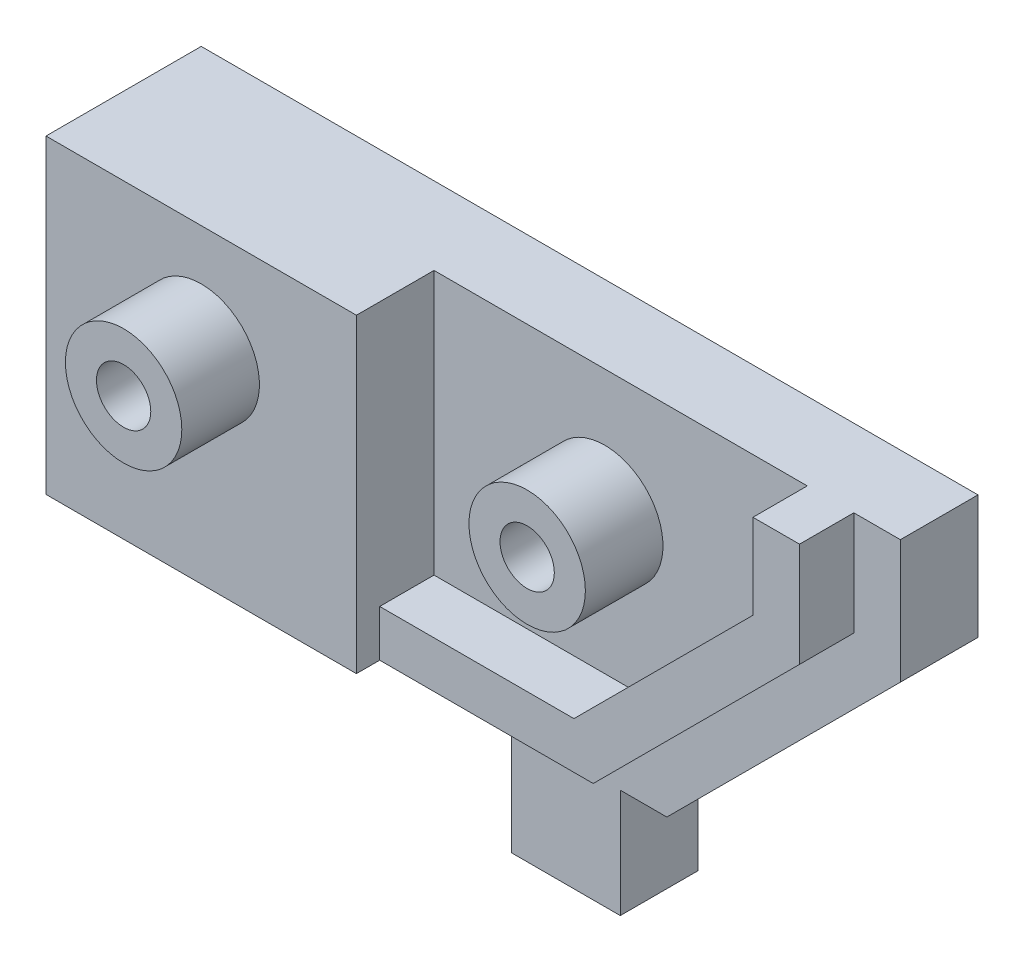
from build123d import *

# Parameters (mm, degrees)
BOSS_EXTRUDE1_DEPTH = 23
SKETCH2_R           = 1.75
CUT_EXTRUDE1_DEPTH  = 11
SKETCH3_R           = 1.5
CUT_EXTRUDE2_DEPTH  = 10
SKETCH4_W           = 7
SKETCH4_H           = 5
BOSS_EXTRUDE2_DEPTH = 7
SKETCH5_R           = 3.75
SKETCH5_R_2         = 1.75
BOSS_EXTRUDE3_DEPTH = 5
SKETCH6_R           = 3.75
SKETCH6_R_2         = 1.75
BOSS_EXTRUDE4_DEPTH = 5
BOSS_EXTRUDE5_DEPTH = 5
BOSS_EXTRUDE6_DEPTH = 3.5
SKETCH9_W           = 5
SKETCH9_H           = 3
CUT_EXTRUDE3_DEPTH  = 20


with BuildPart() as part:
    # Sketch1 → Boss-Extrude1 (new body)
    with BuildSketch(Plane(origin=(0, 0, 0), x_dir=(1, 0, 0), z_dir=(0, 1, 0))):
        Polygon((0, 0), (-18, 0), (-22, 0), (-35, 0), (-35, -5), (-35, -10), (-15, -10), (-15, -5), (0, -5), align=None)
    extrude(amount=BOSS_EXTRUDE1_DEPTH)

    # Sketch2 → Cut-Extrude1 (cut, through all)
    with BuildSketch(Plane.XY.offset(10)):
        with Locations((-25, 16)):
            Circle(SKETCH2_R)
        with Locations((-4, 15)):
            Circle(SKETCH2_R)
    extrude(amount=-CUT_EXTRUDE1_DEPTH, mode=Mode.SUBTRACT)

    # Sketch3 → Cut-Extrude2 (cut)
    with BuildSketch(Plane.XZ):
        with Locations((-25, 2.5)):
            Circle(SKETCH3_R)
    extrude(amount=-CUT_EXTRUDE2_DEPTH, mode=Mode.SUBTRACT)

    # Sketch4 → Boss-Extrude2 (add)
    with BuildSketch(Plane.XZ):
        with Locations((-6.5, 2.5)):
            Rectangle(SKETCH4_W, SKETCH4_H)
    extrude(amount=BOSS_EXTRUDE2_DEPTH)

    # Sketch5 → Boss-Extrude3 (add)
    with BuildSketch(Plane.XY.offset(10)):
        with Locations((-25, 16)):
            Circle(SKETCH5_R)
        with Locations((-25, 16)):
            Circle(SKETCH5_R_2, mode=Mode.SUBTRACT)
    extrude(amount=BOSS_EXTRUDE3_DEPTH)

    # Sketch6 → Boss-Extrude4 (add)
    with BuildSketch(Plane.XY.offset(5)):
        with Locations((-4, 15)):
            Circle(SKETCH6_R)
        with Locations((-4, 15)):
            Circle(SKETCH6_R_2, mode=Mode.SUBTRACT)
    extrude(amount=BOSS_EXTRUDE4_DEPTH)

    # Sketch7 → Boss-Extrude5 (add)
    with BuildSketch(Plane.XY.offset(5)):
        Polygon((0, 0), (0, 23), (15.047232304, 23), (15.047232304, 15.047232304), align=None)
    extrude(amount=-BOSS_EXTRUDE5_DEPTH)

    # Sketch8 → Boss-Extrude6 (add)
    with BuildSketch(Plane.XY.offset(5)):
        Polygon((12.047232304, 23), (12.047232304, 16.289872991), (-1.242640687, 3), (-15, 3), (-15, 6), (-2.485281374, 6), (9.047232304, 17.532513678), (9.047232304, 23), align=None)
    extrude(amount=BOSS_EXTRUDE6_DEPTH)

    # Sketch9 → Cut-Extrude3 (cut)
    with BuildSketch(Plane(origin=(-15, 0, 0), x_dir=(0, 0, -1), z_dir=(1, 0, 0))):
        with Locations((-7.5, 1.5)):
            Rectangle(SKETCH9_W, SKETCH9_H)
    extrude(amount=-CUT_EXTRUDE3_DEPTH, mode=Mode.SUBTRACT)


solid = part.part
